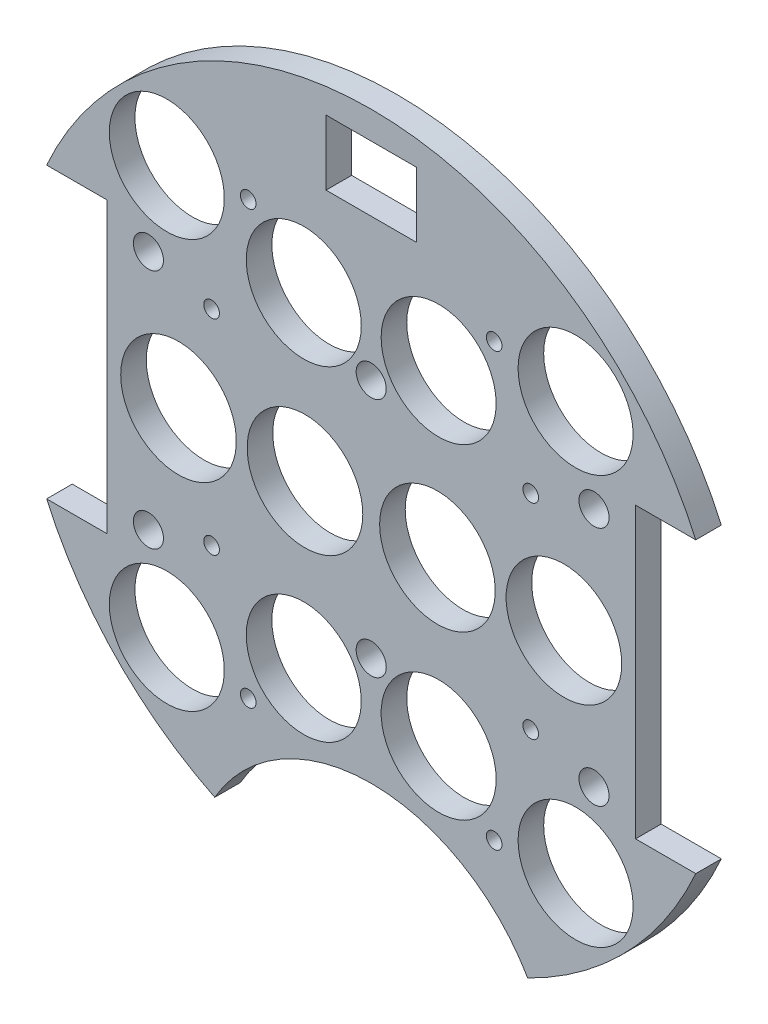
from build123d import *

# Parameters (mm, degrees)
BOSS_EXTRUDE2_DEPTH      = 5.3975
SKETCH3_R                = 12.192
SKETCH3_R_2              = 12.1285
CUT_EXTRUDE2_DEPTH       = 6.3975
SKETCH5_W                = 19.05
SKETCH5_H                = 13.716
CUT_EXTRUDE3_DEPTH       = 40.64
SKETCH6_R                = 38.1
CUT_EXTRUDE4_DEPTH       = 6.3975
SKETCH11_R               = 1.651
CUT_EXTRUDE9_DEPTH       = 75.692
SKETCH13_R               = 1.651
CUT_EXTRUDE11_DEPTH      = 97.79
SKETCH15_R               = 3.175
CUT_EXTRUDE13_DEPTH      = 103.378
CUT_EXTRUDE13_DEPTH_BACK = 48.768


with BuildPart() as part:
    # Sketch1 → Boss-Extrude2 (new body)
    with BuildSketch(Plane.XY):
        with BuildLine():
            Line((-68.450525929, 30.48), (-55.750525929, 30.48))
            Line((-55.750525929, 30.48), (-55.750525929, -30.48))
            Line((-55.750525929, -30.48), (-68.450525929, -30.48))
            ThreePointArc((-68.450525929, -30.48), (0, -74.93), (68.450525929, -30.48))
            Line((68.450525929, -30.48), (55.750525929, -30.48))
            Line((55.750525929, -30.48), (55.750525929, 30.48))
            Line((55.750525929, 30.48), (68.450525929, 30.48))
            ThreePointArc((68.450525929, 30.48), (0, 74.93), (-68.450525929, 30.48))
        make_face()
    extrude(amount=BOSS_EXTRUDE2_DEPTH)

    # Sketch3 → Cut-Extrude2 (cut, through all)
    with BuildSketch(Plane(origin=(0, 0, 0), x_dir=(-1, 0, 0), z_dir=(0, 0, -1))):
        with Locations((-13.97, 0)):
            Circle(SKETCH3_R)
        with Locations((13.97, 0)):
            Circle(SKETCH3_R)
        with Locations((40.64, 0)):
            Circle(SKETCH3_R)
        with Locations((-43.105229381, -43.105229381)):
            Circle(SKETCH3_R_2)
        with Locations((14.224, -34.29)):
            Circle(SKETCH3_R_2)
        with Locations((14.224, 34.29)):
            Circle(SKETCH3_R_2)
        with Locations((-43.105229381, 43.105229381)):
            Circle(SKETCH3_R_2)
        with Locations((43.105229381, 43.105229381)):
            Circle(SKETCH3_R_2)
        with Locations((-14.224, 34.29)):
            Circle(SKETCH3_R_2)
        with Locations((-14.224, -34.29)):
            Circle(SKETCH3_R_2)
        with Locations((43.105229381, -43.105229381)):
            Circle(SKETCH3_R_2)
        with Locations((-40.64, 0)):
            Circle(SKETCH3_R)
    extrude(amount=-CUT_EXTRUDE2_DEPTH, mode=Mode.SUBTRACT)

    # Sketch5 → Cut-Extrude3 (cut)
    with BuildSketch(Plane(origin=(0, 0, 0), x_dir=(-1, 0, 0), z_dir=(0, 0, -1))):
        with Locations((0, 62.23)):
            Rectangle(SKETCH5_W, SKETCH5_H)
    extrude(amount=-CUT_EXTRUDE3_DEPTH, mode=Mode.SUBTRACT)

    # Sketch6 → Cut-Extrude4 (cut, through all)
    with BuildSketch(Plane.XY.offset(5.3975)):
        with Locations((0, -86.312058398)):
            Circle(SKETCH6_R)
    extrude(amount=-CUT_EXTRUDE4_DEPTH, mode=Mode.SUBTRACT)

    # Sketch11 → Cut-Extrude9 (cut)
    with BuildSketch(Plane(origin=(30.092005081, 4.08352975, -6.096), x_dir=(-1, 0, 0), z_dir=(0, 0, -1))):
        with Locations((63.757223581, 17.50647025)):
            Circle(SKETCH11_R)
        with Locations((63.757223581, -25.67352975)):
            Circle(SKETCH11_R)
        with Locations((-3.552776419, -25.67352975)):
            Circle(SKETCH11_R)
        with Locations((-3.552776419, 17.50647025)):
            Circle(SKETCH11_R)
    extrude(amount=-CUT_EXTRUDE9_DEPTH, mode=Mode.SUBTRACT)

    # Sketch13 → Cut-Extrude11 (cut)
    with BuildSketch(Plane(origin=(30.092005081, 4.08352975, -36.1315), x_dir=(-1, 0, 0), z_dir=(0, 0, -1))):
        with Locations((4.154396091, -49.728759131)):
            Circle(SKETCH13_R)
        with Locations((56.02961407, -49.728759131)):
            Circle(SKETCH13_R)
        with Locations((4.154396091, 41.38247025)):
            Circle(SKETCH13_R)
        with Locations((56.02961407, 41.38247025)):
            Circle(SKETCH13_R)
    extrude(amount=-CUT_EXTRUDE11_DEPTH, mode=Mode.SUBTRACT)

    # Sketch15 → Cut-Extrude13 (cut, two sides)
    with BuildSketch(Plane(origin=(30.092005081, 4.08352975, 0), x_dir=(-1, 0, 0), z_dir=(0, 0, -1))) as cut_extrude13_sk:
        with Locations((-16.897994919, 21.31647025)):
            Circle(SKETCH15_R)
        with Locations((77.082005081, 21.31647025)):
            Circle(SKETCH15_R)
        with Locations((30.092005081, 21.31647025)):
            Circle(SKETCH15_R)
        with Locations((77.082005081, -29.48352975)):
            Circle(SKETCH15_R)
        with Locations((30.092005081, -29.48352975)):
            Circle(SKETCH15_R)
        with Locations((-16.897994919, -29.48352975)):
            Circle(SKETCH15_R)
    extrude(amount=CUT_EXTRUDE13_DEPTH, mode=Mode.SUBTRACT)
    extrude(cut_extrude13_sk.sketch, amount=-CUT_EXTRUDE13_DEPTH_BACK, mode=Mode.SUBTRACT)


solid = part.part
